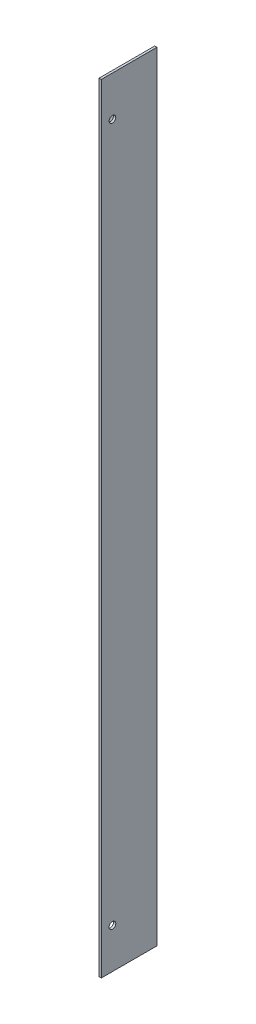
from build123d import *

# Parameters (mm, degrees)
CROQUIS2_W              = 1
CROQUIS2_H              = 350
SALIENTE_EXTRUIR2_DEPTH = 25
CROQUIS5_R              = 1.5
CORTAR_EXTRUIR2_DEPTH   = 1
CROQUIS1_R              = 1.5
SALIENTE_EXTRUIR3_DEPTH = 1


with BuildPart() as part:
    # Croquis2 → Saliente-Extruir2 (new body)
    with BuildSketch(Plane.XY):
        with Locations((-54.941785307, -113.819624774)):
            Rectangle(CROQUIS2_W, CROQUIS2_H)
    extrude(amount=SALIENTE_EXTRUIR2_DEPTH)

    # Croquis5 → Cortar-Extruir2 (cut)
    with BuildSketch(Plane(origin=(-54.441785307, 0, 0), x_dir=(0, 0, -1), z_dir=(1, 0, 0))):
        with Locations((-20, 43.180375226)):
            Circle(CROQUIS5_R)
        with Locations((-20, -270.819624774)):
            Circle(CROQUIS5_R)
    extrude(amount=-CORTAR_EXTRUIR2_DEPTH, mode=Mode.SUBTRACT)

    # Croquis1 → Saliente-Extruir3 (add)
    with BuildSketch(Plane.XY):
        Polygon((-55.441785307, 61.180375226), (-79.441785307, 37.180375226), (-79.441785307, -264.819624774), (-55.441785307, -288.819624774), align=None)
        with Locations((-74.441785307, 21.180375226)):
            Circle(CROQUIS1_R, mode=Mode.SUBTRACT)
        with Locations((-74.441785307, -248.819624774)):
            Circle(CROQUIS1_R, mode=Mode.SUBTRACT)
        with Locations((-74.441785307, -58.819624774)):
            Circle(CROQUIS1_R, mode=Mode.SUBTRACT)
    extrude(amount=SALIENTE_EXTRUIR3_DEPTH)


solid = part.part
